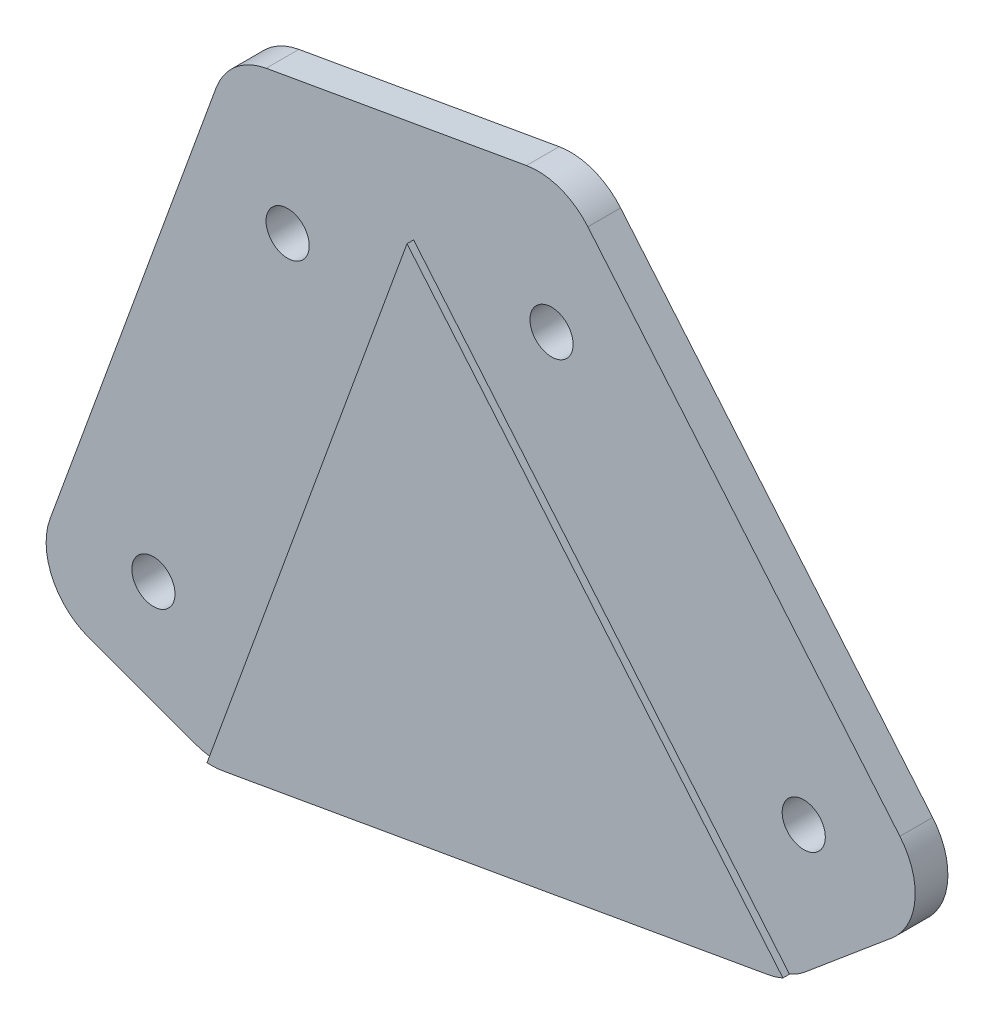
from build123d import *

# Parameters (mm, degrees)
EXTRUDE_1_DEPTH     = 3
SKETCH_2_R          = 1.65
CUT_EXTRUDE_1_DEPTH = 3
FILLET_1_R          = 5
CUT_EXTRUDE_2_DEPTH = 0.5


with BuildPart() as part:
    # ｽｹｯﾁ1 → ﾎﾞｽ - 押し出し1 (new body)
    with BuildSketch(Plane.XY):
        Polygon((173.531323483, 340.900859956), (144.605881047, 375.372859896), (133.1152144, 365.731045751), (119.019825089, 370.861347901), (103.628918639, 328.575179965), (117.724307951, 323.444877815), (162.040656836, 331.259045811), align=None)
        Polygon((144.605881047, 375.372859896), (133.1152144, 365.731045751), (119.019825089, 370.861347901), align=None)
    extrude(amount=EXTRUDE_1_DEPTH)

    # ｽｹｯﾁ2 → ｶｯﾄ - 押し出し1 (cut)
    with BuildSketch(Plane.XY.offset(3)):
        with Locations((113.24176437, 333.057723546)):
            Circle(SKETCH_2_R)
        with Locations((123.50236867, 361.24850217)):
            Circle(SKETCH_2_R)
        with Locations((143.681454796, 364.8066195)):
            Circle(SKETCH_2_R)
        with Locations((162.965083087, 341.825286207)):
            Circle(SKETCH_2_R)
    extrude(amount=-CUT_EXTRUDE_1_DEPTH, mode=Mode.SUBTRACT)

    # ﾌｨﾚｯﾄ1
    fillet_1_edges = [part.edges().sort_by_distance(p)[0] for p in [
        (173.531323483, 340.900859956, 1.5),
        (162.040656836, 331.259045811, 1.5),
        (117.724307951, 323.444877815, 1.5),
        (103.628918639, 328.575179965, 1.5),
        (119.019825089, 370.861347901, 1.5),
        (144.605881047, 375.372859896, 1.5),
    ]]
    fillet(fillet_1_edges, radius=FILLET_1_R)

    # ｽｹｯﾁ3 → ｶｯﾄ - 押し出し2 (cut)
    with BuildSketch(Plane.XY.offset(3)):
        Polygon((121.413966092, 377.439196246), (103.628918639, 328.575179965), (117.771292582, 323.427776808), (133.132579218, 365.632564976), (162.002354614, 331.22690643), (173.531323483, 340.900859956), (140.106367779, 380.735170998), (131.711632891, 373.691152049), align=None)
    extrude(amount=-CUT_EXTRUDE_2_DEPTH, mode=Mode.SUBTRACT)


solid = part.part
